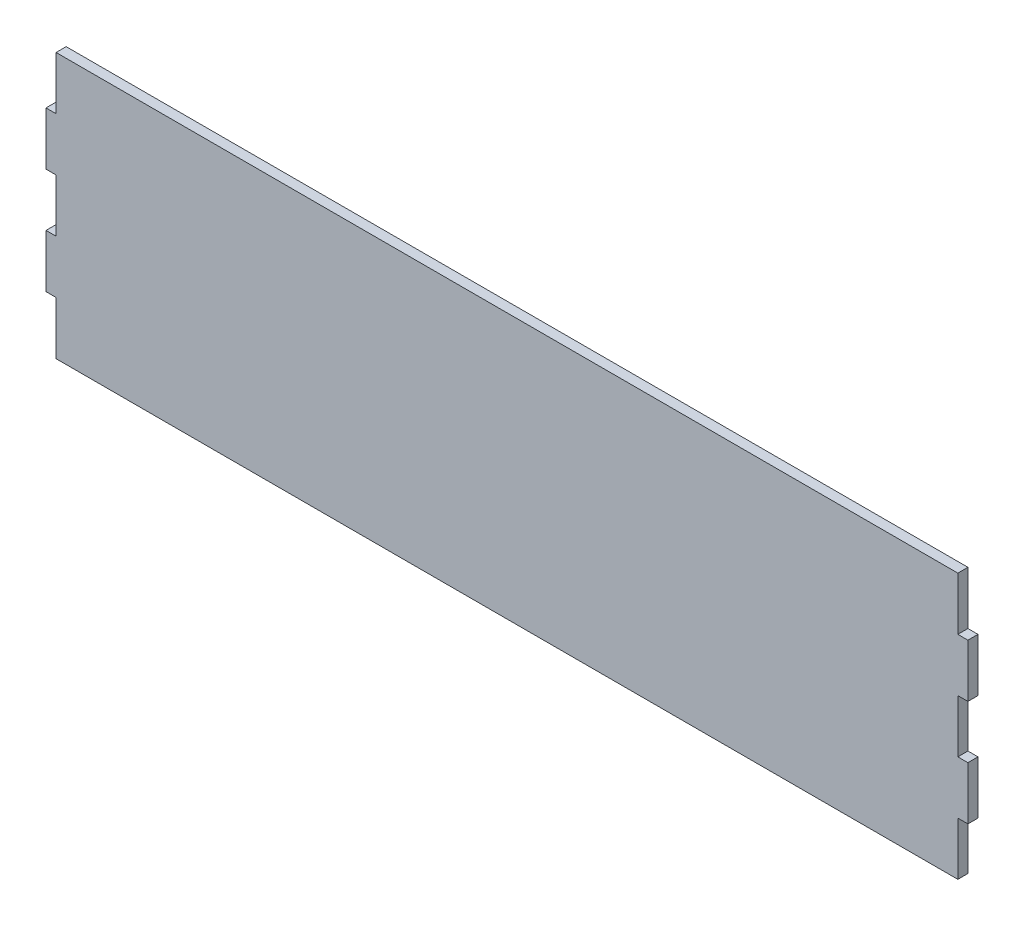
from build123d import *

# Parameters (mm, degrees)
BOSS_EXTRUDE1_DEPTH = 4.826


with BuildPart() as part:
    # Sketch1 → Boss-Extrude1 (new body)
    with BuildSketch(Plane.XY):
        Polygon((0, 76.2), (0, 50.8), (-4.826, 50.8), (-4.826, 25.4), (0, 25.4), (0, 0), (431.8, 0), (431.8, 25.4), (436.626, 25.4), (436.626, 50.8), (431.8, 50.8), (431.8, 76.2), (436.626, 76.2), (436.626, 101.6), (431.8, 101.6), (431.8, 127), (0, 127), (0, 101.6), (-4.826, 101.6), (-4.826, 76.2), align=None)
    extrude(amount=BOSS_EXTRUDE1_DEPTH)


solid = part.part
